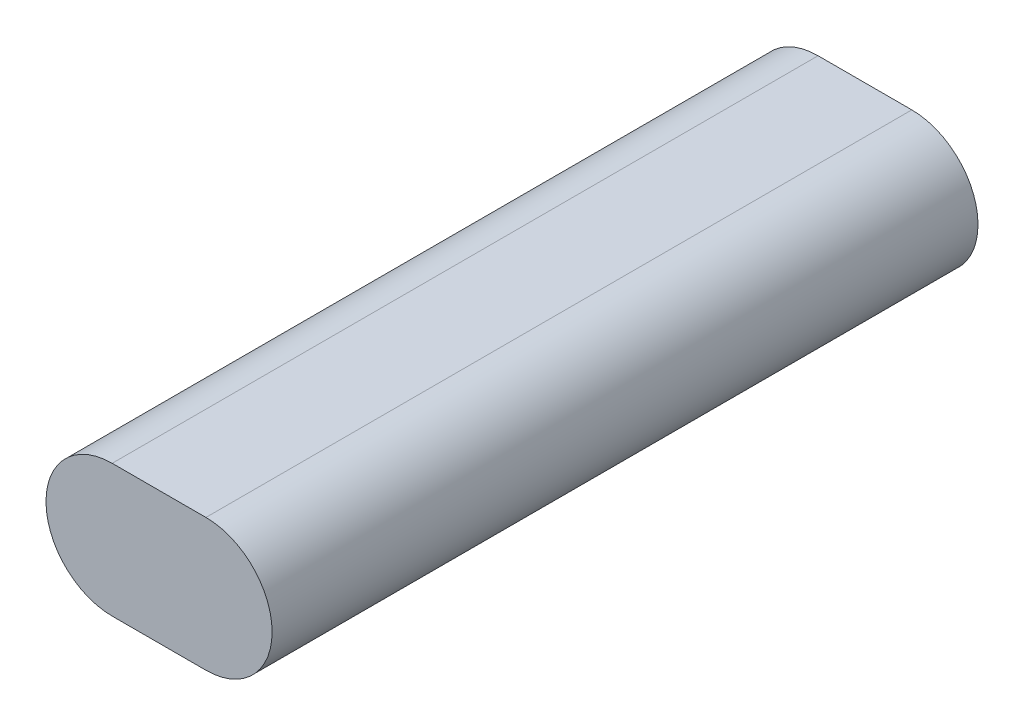
from build123d import *

# Parameters (mm, degrees)
AUFSATZ_LINEAR_AUSTRAGEN1_DEPTH = 128


with BuildPart() as part:
    # Skizze1 → Aufsatz-Linear austragen1 (new body)
    with BuildSketch(Plane.XY):
        with BuildLine():
            Line((-8.5, 12), (8.5, 12))
            ThreePointArc((8.5, 12), (20.5, 0), (8.5, -12))
            Line((8.5, -12), (-8.5, -12))
            ThreePointArc((-8.5, -12), (-20.5, 0), (-8.5, 12))
        make_face()
    extrude(amount=AUFSATZ_LINEAR_AUSTRAGEN1_DEPTH)


solid = part.part
